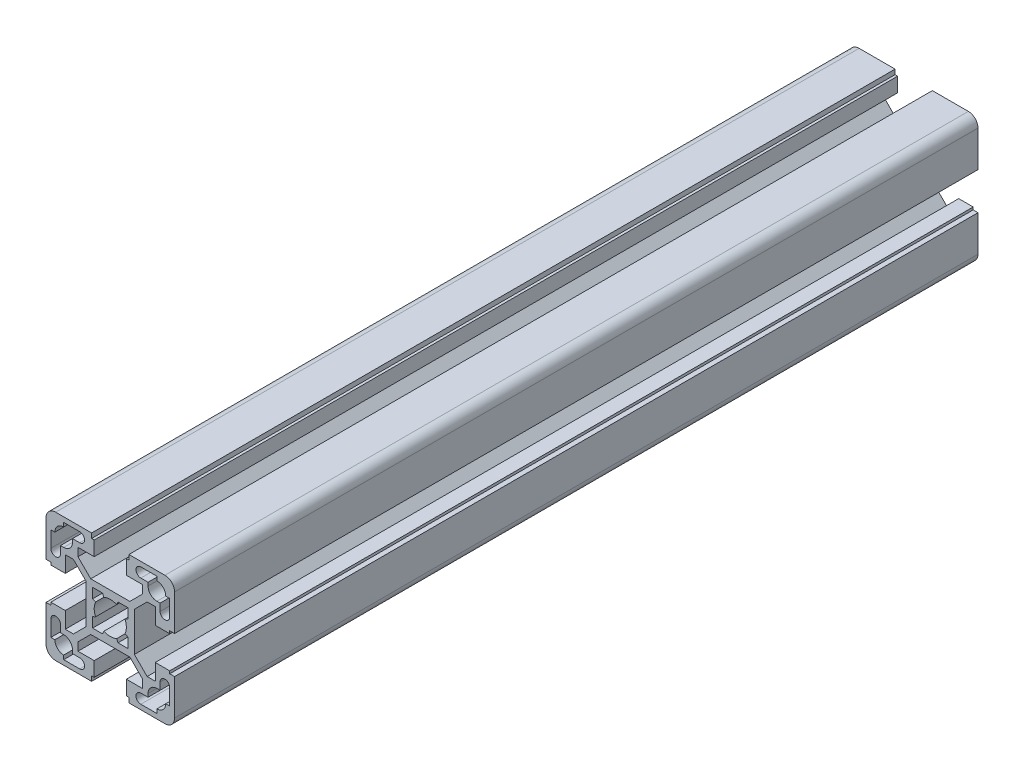
from build123d import *

# Parameters (mm, degrees)
EXTRUDE1_DEPTH = 125


with BuildPart() as part:
    # Sketch1 → Extrude1 (new body, symmetric)
    with BuildSketch(Plane.XY):
        with BuildLine():
            Line((5.8, -20), (17, -20))
            ThreePointArc((17, -20), (19.121320344, -19.121320344), (20, -17))
            Line((20, -17), (20, -5.8))
            Line((20, -5.8), (18.5, -5.8))
            Line((18.5, -5.8), (18.5, -5))
            Line((18.5, -5), (14, -5))
            Line((14, -5), (14, -10.05))
            Line((14, -10.05), (11.464213562, -10.05))
            Line((11.464213562, -10.05), (7.5, -6.085786438))
            Line((7.5, -6.085786438), (7.5, 6.085786438))
            Line((7.5, 6.085786438), (11.464213562, 10.05))
            Line((11.464213562, 10.05), (14, 10.05))
            Line((14, 10.05), (14, 5))
            Line((14, 5), (18.5, 5))
            Line((18.5, 5), (18.5, 5.8))
            Line((18.5, 5.8), (20, 5.8))
            Line((20, 5.8), (20, 17))
            ThreePointArc((20, 17), (19.121320344, 19.121320344), (17, 20))
            Line((17, 20), (5.8, 20))
            Line((5.8, 20), (5.8, 18.5))
            Line((5.8, 18.5), (5, 18.5))
            Line((5, 18.5), (5, 14))
            Line((5, 14), (10.05, 14))
            Line((10.05, 14), (10.05, 11.464213562))
            Line((10.05, 11.464213562), (6.085786438, 7.5))
            Line((6.085786438, 7.5), (-6.085786438, 7.5))
            Line((-6.085786438, 7.5), (-10.05, 11.464213562))
            Line((-10.05, 11.464213562), (-10.05, 14))
            Line((-10.05, 14), (-5, 14))
            Line((-5, 14), (-5, 18.5))
            Line((-5, 18.5), (-5.8, 18.5))
            Line((-5.8, 18.5), (-5.8, 20))
            Line((-5.8, 20), (-17, 20))
            ThreePointArc((-17, 20), (-19.121320344, 19.121320344), (-20, 17))
            Line((-20, 17), (-20, 5.8))
            Line((-20, 5.8), (-18.5, 5.8))
            Line((-18.5, 5.8), (-18.5, 5))
            Line((-18.5, 5), (-14, 5))
            Line((-14, 5), (-14, 10.05))
            Line((-14, 10.05), (-11.464213562, 10.05))
            Line((-11.464213562, 10.05), (-7.5, 6.085786438))
            Line((-7.5, 6.085786438), (-7.5, -6.085786438))
            Line((-7.5, -6.085786438), (-11.464213562, -10.05))
            Line((-11.464213562, -10.05), (-14, -10.05))
            Line((-14, -10.05), (-14, -5))
            Line((-14, -5), (-18.5, -5))
            Line((-18.5, -5), (-18.5, -5.8))
            Line((-18.5, -5.8), (-20, -5.8))
            Line((-20, -5.8), (-20, -17))
            ThreePointArc((-20, -17), (-19.121320344, -19.121320344), (-17, -20))
            Line((-17, -20), (-5.8, -20))
            Line((-5.8, -20), (-5.8, -18.5))
            Line((-5.8, -18.5), (-5, -18.5))
            Line((-5, -18.5), (-5, -14))
            Line((-5, -14), (-10.05, -14))
            Line((-10.05, -14), (-10.05, -11.464213562))
            Line((-10.05, -11.464213562), (-6.085786438, -7.5))
            Line((-6.085786438, -7.5), (6.085786438, -7.5))
            Line((6.085786438, -7.5), (10.05, -11.464213562))
            Line((10.05, -11.464213562), (10.05, -14))
            Line((10.05, -14), (5, -14))
            Line((5, -14), (5, -18.5))
            Line((5, -18.5), (5.8, -18.5))
            Line((5.8, -18.5), (5.8, -20))
        make_face()
        with BuildLine():
            Line((14.5, -18.5), (9.5, -18.5))
            ThreePointArc((9.5, -18.5), (8, -17), (9.5, -15.5))
            Line((9.5, -15.5), (11.75, -15.5))
            Line((11.75, -15.5), (11.75, -14.5))
            ThreePointArc((11.75, -14.5), (12.555456352, -12.555456352), (14.5, -11.75))
            Line((14.5, -11.75), (15.5, -11.75))
            Line((15.5, -11.75), (15.5, -9.5))
            ThreePointArc((15.5, -9.5), (17, -8), (18.5, -9.5))
            Line((18.5, -9.5), (18.5, -14.5))
            Line((18.5, -14.5), (17.25, -14.5))
            ThreePointArc((17.25, -14.5), (16.444543648, -16.444543648), (14.5, -17.25))
            Line((14.5, -17.25), (14.5, -18.5))
        make_face(mode=Mode.SUBTRACT)
        with BuildLine():
            Line((18.5, 14.5), (17.25, 14.5))
            ThreePointArc((17.25, 14.5), (16.444543648, 16.444543648), (14.5, 17.25))
            Line((14.5, 17.25), (14.5, 18.5))
            Line((14.5, 18.5), (9.5, 18.5))
            ThreePointArc((9.5, 18.5), (8, 17), (9.5, 15.5))
            Line((9.5, 15.5), (11.75, 15.5))
            Line((11.75, 15.5), (11.75, 14.5))
            ThreePointArc((11.75, 14.5), (12.555456352, 12.555456352), (14.5, 11.75))
            Line((14.5, 11.75), (15.5, 11.75))
            Line((15.5, 11.75), (15.5, 9.5))
            ThreePointArc((15.5, 9.5), (17, 8), (18.5, 9.5))
            Line((18.5, 9.5), (18.5, 14.5))
        make_face(mode=Mode.SUBTRACT)
        with BuildLine():
            Line((5.5, 5.5), (2.397915762, 5.5))
            Line((2.397915762, 5.5), (1.998263135, 4.583333333))
            ThreePointArc((1.998263135, 4.583333333), (0, 5), (-1.998263135, 4.583333333))
            Line((-1.998263135, 4.583333333), (-2.397915762, 5.5))
            Line((-2.397915762, 5.5), (-5.5, 5.5))
            Line((-5.5, 5.5), (-5.5, 2.397915762))
            Line((-5.5, 2.397915762), (-4.583333333, 1.998263135))
            ThreePointArc((-4.583333333, 1.998263135), (-5, 0), (-4.583333333, -1.998263135))
            Line((-4.583333333, -1.998263135), (-5.5, -2.397915762))
            Line((-5.5, -2.397915762), (-5.5, -5.5))
            Line((-5.5, -5.5), (-2.397915762, -5.5))
            Line((-2.397915762, -5.5), (-1.998263135, -4.583333333))
            ThreePointArc((-1.998263135, -4.583333333), (0, -5), (1.998263135, -4.583333333))
            Line((1.998263135, -4.583333333), (2.397915762, -5.5))
            Line((2.397915762, -5.5), (5.5, -5.5))
            Line((5.5, -5.5), (5.5, -2.397915762))
            Line((5.5, -2.397915762), (4.583333333, -1.998263135))
            ThreePointArc((4.583333333, -1.998263135), (5, 0), (4.583333333, 1.998263135))
            Line((4.583333333, 1.998263135), (5.5, 2.397915762))
            Line((5.5, 2.397915762), (5.5, 5.5))
        make_face(mode=Mode.SUBTRACT)
        with BuildLine():
            Line((-18.5, -14.5), (-17.25, -14.5))
            ThreePointArc((-17.25, -14.5), (-16.444543648, -16.444543648), (-14.5, -17.25))
            Line((-14.5, -17.25), (-14.5, -18.5))
            Line((-14.5, -18.5), (-9.5, -18.5))
            ThreePointArc((-9.5, -18.5), (-8, -17), (-9.5, -15.5))
            Line((-9.5, -15.5), (-11.75, -15.5))
            Line((-11.75, -15.5), (-11.75, -14.5))
            ThreePointArc((-11.75, -14.5), (-12.555456352, -12.555456352), (-14.5, -11.75))
            Line((-14.5, -11.75), (-15.5, -11.75))
            Line((-15.5, -11.75), (-15.5, -9.5))
            ThreePointArc((-15.5, -9.5), (-17, -8), (-18.5, -9.5))
            Line((-18.5, -9.5), (-18.5, -14.5))
        make_face(mode=Mode.SUBTRACT)
        with BuildLine():
            Line((-14.5, 18.5), (-9.5, 18.5))
            ThreePointArc((-9.5, 18.5), (-8, 17), (-9.5, 15.5))
            Line((-9.5, 15.5), (-11.75, 15.5))
            Line((-11.75, 15.5), (-11.75, 14.5))
            ThreePointArc((-11.75, 14.5), (-12.555456352, 12.555456352), (-14.5, 11.75))
            Line((-14.5, 11.75), (-15.5, 11.75))
            Line((-15.5, 11.75), (-15.5, 9.5))
            ThreePointArc((-15.5, 9.5), (-17, 8), (-18.5, 9.5))
            Line((-18.5, 9.5), (-18.5, 14.5))
            Line((-18.5, 14.5), (-17.25, 14.5))
            ThreePointArc((-17.25, 14.5), (-16.444543648, 16.444543648), (-14.5, 17.25))
            Line((-14.5, 17.25), (-14.5, 18.5))
        make_face(mode=Mode.SUBTRACT)
    extrude(amount=EXTRUDE1_DEPTH, both=True)


solid = part.part
